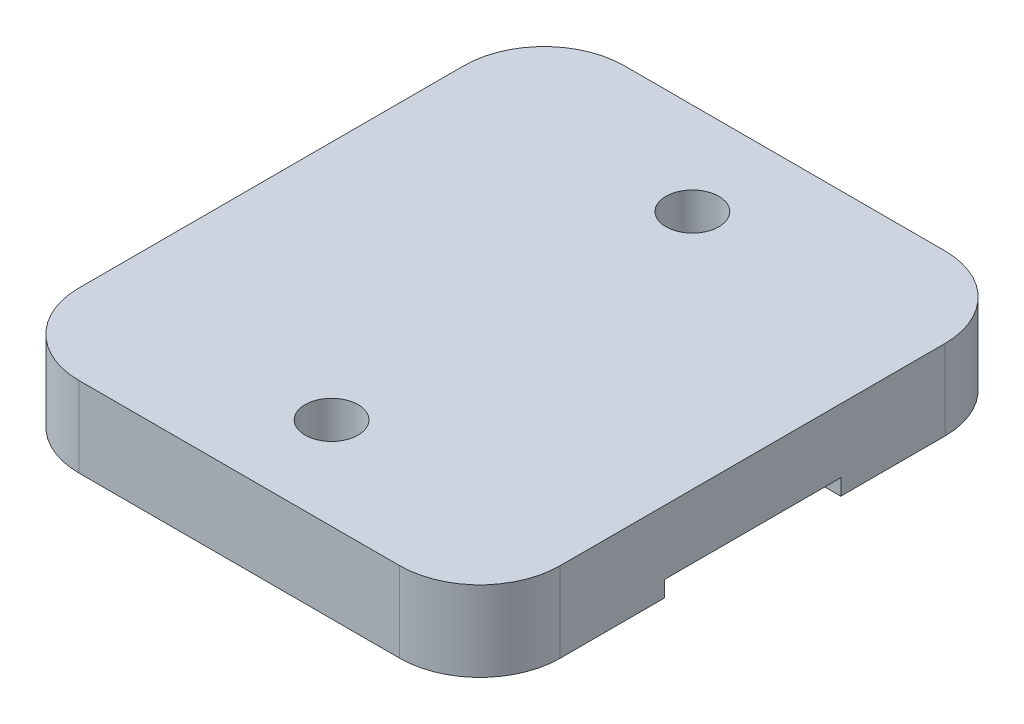
from build123d import *

# Parameters (mm, degrees)
SKETCH1_W           = 30
SKETCH1_H           = 34
BOSS_EXTRUDE1_DEPTH = 5
SKETCH2_W           = 11
SKETCH2_H           = 1
CUT_EXTRUDE1_DEPTH  = 31
FILLET1_R           = 5
SKETCH6_R           = 1.65
CUT_EXTRUDE2_DEPTH  = 6


with BuildPart() as part:
    # Sketch1 → Boss-Extrude1 (new body)
    with BuildSketch(Plane.XZ.offset(5)):
        Rectangle(SKETCH1_W, SKETCH1_H)
    extrude(amount=-BOSS_EXTRUDE1_DEPTH)

    # Sketch2 → Cut-Extrude1 (cut, through all)
    with BuildSketch(Plane.ZY.offset(15)):
        with Locations((0, -4.5)):
            Rectangle(SKETCH2_W, SKETCH2_H)
    extrude(amount=-CUT_EXTRUDE1_DEPTH, mode=Mode.SUBTRACT)

    # Fillet1
    fillet1_edges = [part.edges().sort_by_distance(p)[0] for p in [
        (15, -2.5, 17),
        (15, -2.5, -17),
        (-15, -2.5, -17),
        (-15, -2.5, 17),
    ]]
    fillet(fillet1_edges, radius=FILLET1_R)

    # Sketch6 → Cut-Extrude2 (cut, through all)
    with BuildSketch(Plane.XZ.offset(5)):
        with Locations((0, 11.25)):
            Circle(SKETCH6_R)
        with Locations((0, -11.25)):
            Circle(SKETCH6_R)
    extrude(amount=-CUT_EXTRUDE2_DEPTH, mode=Mode.SUBTRACT)


solid = part.part
